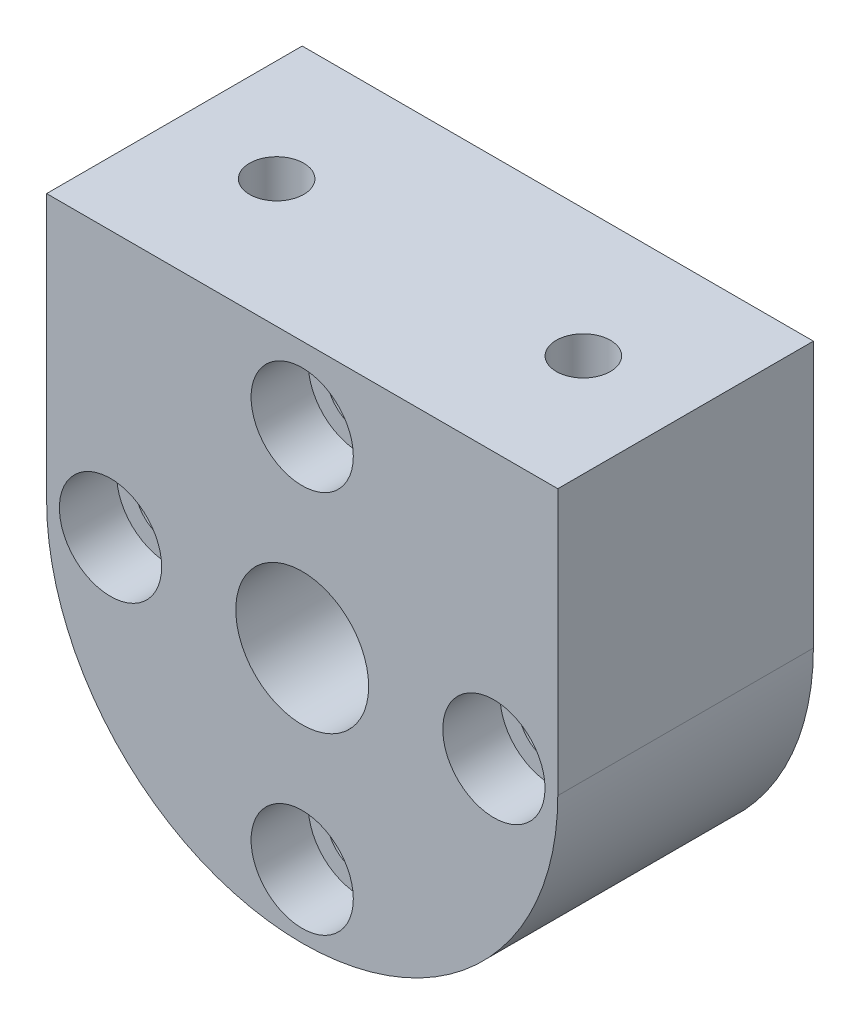
from build123d import *

# Parameters (mm, degrees)
BOSS_EXTRUDE1_DEPTH                            = 12.7
SKETCH2_R                                      = 3.302
CUT_EXTRUDE1_DEPTH                             = 12.7
CBORE_FOR_4_SOCKET_HEAD_CAP_SCREW1_D           = 3.2639
CBORE_FOR_4_SOCKET_HEAD_CAP_SCREW1_CBORE_D     = 5.08
CBORE_FOR_4_SOCKET_HEAD_CAP_SCREW1_CBORE_DEPTH = 2.8448
SKETCH9_R                                      = 1.3462
CUT_EXTRUDE3_DEPTH                             = 8.89


with BuildPart() as part:
    # Sketch1 → Boss-Extrude1 (new body)
    with BuildSketch(Plane.XY):
        with BuildLine():
            Line((-12.7, 0), (-12.7, 13.208))
            Line((-12.7, 13.208), (12.7, 13.208))
            Line((12.7, 13.208), (12.7, 0))
            ThreePointArc((12.7, 0), (0, -12.7), (-12.7, 0))
        make_face()
    extrude(amount=BOSS_EXTRUDE1_DEPTH)

    # Sketch2 → Cut-Extrude1 (cut)
    with BuildSketch(Plane.XY.offset(12.7)):
        Circle(SKETCH2_R)
    extrude(amount=-CUT_EXTRUDE1_DEPTH, mode=Mode.SUBTRACT)

    # CBORE for #4 Socket Head Cap Screw1 (through all)
    with Locations(Plane.XY.offset(12.7)):
        with Locations((-9.525, 0), (0, 9.525), (9.525, 0), (0, -9.525)):
            CounterBoreHole(CBORE_FOR_4_SOCKET_HEAD_CAP_SCREW1_D / 2, CBORE_FOR_4_SOCKET_HEAD_CAP_SCREW1_CBORE_D / 2, CBORE_FOR_4_SOCKET_HEAD_CAP_SCREW1_CBORE_DEPTH)

    # Sketch9 → Cut-Extrude3 (cut)
    with BuildSketch(Plane(origin=(0, 13.208, 0), x_dir=(1, 0, 0), z_dir=(0, 1, 0))):
        with Locations((-7.62, -6.35)):
            Circle(SKETCH9_R)
        with Locations((7.62, -6.35)):
            Circle(SKETCH9_R)
    extrude(amount=-CUT_EXTRUDE3_DEPTH, mode=Mode.SUBTRACT)


solid = part.part
